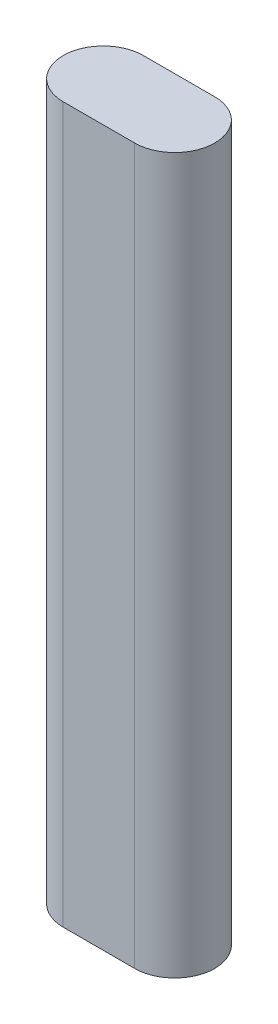
from build123d import *

# Parameters (mm, degrees)
BOSS_EXTRUDE1_DEPTH = 2500


with BuildPart() as part:
    # Sketch1 → Boss-Extrude1 (new body)
    with BuildSketch(Plane(origin=(0, 0, 0), x_dir=(1, 0, 0), z_dir=(0, 1, 0))):
        with BuildLine():
            Line((125, -140), (-125, -140))
            ThreePointArc((-125, -140), (-265, 0), (-125, 140))
            Line((-125, 140), (125, 140))
            ThreePointArc((125, 140), (265, 0), (125, -140))
        make_face()
    extrude(amount=BOSS_EXTRUDE1_DEPTH)


solid = part.part
